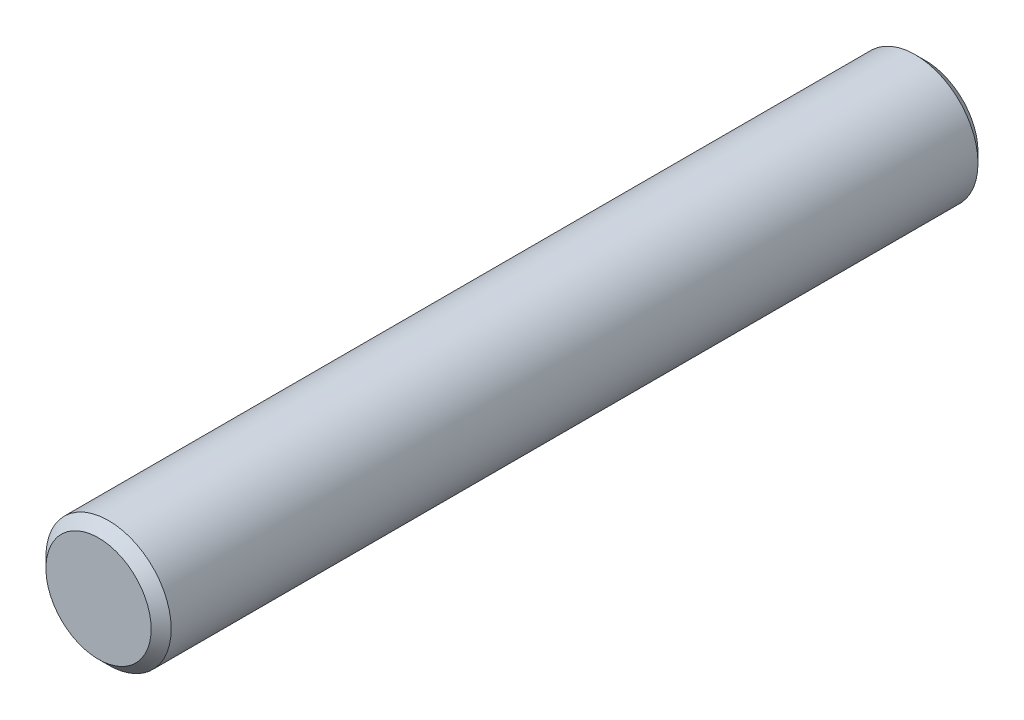
from build123d import *

# Parameters (mm, degrees)
SKETCH1_R           = 2.5
BOSS_EXTRUDE1_DEPTH = 33
CHAMFER1_SIZE       = 0.4


with BuildPart() as part:
    # Sketch1 → Boss-Extrude1 (new body)
    with BuildSketch(Plane.XY):
        Circle(SKETCH1_R)
    extrude(amount=BOSS_EXTRUDE1_DEPTH)

    # Chamfer1
    chamfer1_edges = [part.edges().sort_by_distance(p)[0] for p in [
        (-2.5, 0, 0),
        (-2.5, 0, 33),
    ]]
    chamfer(chamfer1_edges, length=CHAMFER1_SIZE)


solid = part.part
